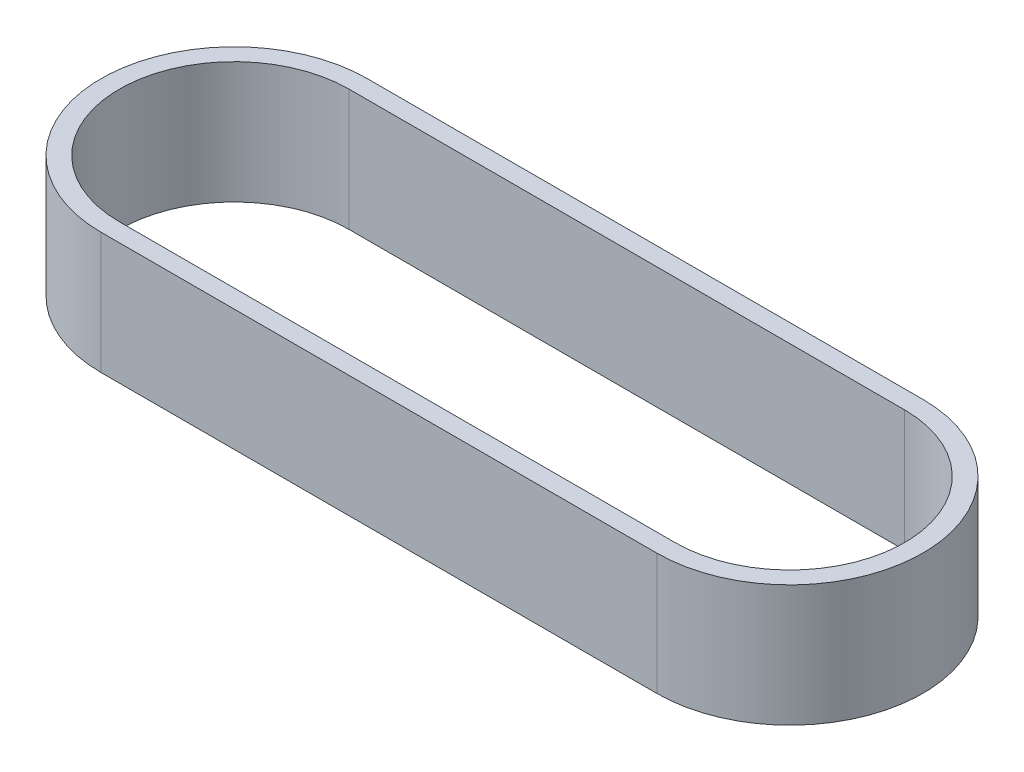
from build123d import *

# Parameters (mm, degrees)
BOSS_EXTRUDE1_DEPTH = 10


with BuildPart() as part:
    # Sketch2 → Boss-Extrude1 (new body)
    with BuildSketch(Plane(origin=(0, 0, 0), x_dir=(1, 0, 0), z_dir=(0, 1, 0))):
        with BuildLine():
            Line((0, 10.95), (45.72, 10.95))
            ThreePointArc((45.72, 10.95), (56.67, 0), (45.72, -10.95))
            Line((45.72, -10.95), (0, -10.95))
            ThreePointArc((0, -10.95), (-10.95, 0), (0, 10.95))
        make_face()
        with BuildLine():
            Line((0, 9.45), (45.72, 9.45))
            ThreePointArc((45.72, 9.45), (55.17, 0), (45.72, -9.45))
            Line((45.72, -9.45), (0, -9.45))
            ThreePointArc((0, -9.45), (-9.45, 0), (0, 9.45))
        make_face(mode=Mode.SUBTRACT)
    extrude(amount=BOSS_EXTRUDE1_DEPTH)


solid = part.part
